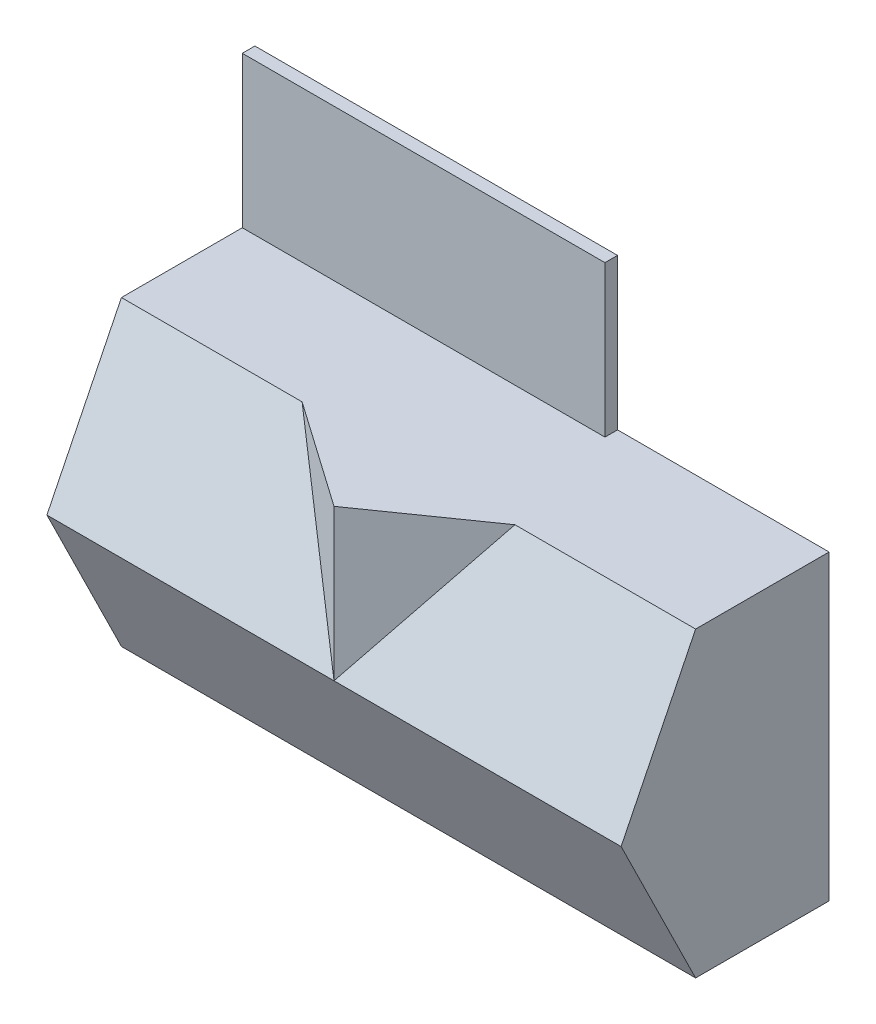
from build123d import *

# Parameters (mm, degrees)
SKETCH3_W           = 11582.4
SKETCH3_H           = 6096
SKETCH3_W_2         = 4341.154286856
SKETCH3_H_2         = 914.4
SKETCH3_W_3         = 1676.4
SKETCH3_H_3         = 2330.801356814
SKETCH3_W_4         = 2663.595025017
SKETCH3_H_4         = 2342.798643186
SKETCH3_W_5         = 1043.645713144
SKETCH3_W_6         = 4013.2
SKETCH3_W_7         = 3708.4
BOSS_EXTRUDE1_DEPTH = 2438.4
SKETCH4_W           = 11582.4
SKETCH4_H           = 6096
BOSS_EXTRUDE2_DEPTH = 254
SKETCH5_W           = 3178.404974983
SKETCH5_H           = 101.6
BOSS_EXTRUDE3_DEPTH = 1016
BOSS_EXTRUDE4_DEPTH = 11582.4
BOSS_EXTRUDE5_REACH = 6098
SKETCH8_W           = 7315.2
SKETCH8_H           = 3048
BOSS_EXTRUDE6_DEPTH = 254


with BuildPart() as part:
    # Sketch3 → Boss-Extrude1 (new body)
    with BuildSketch(Plane.XY):
        with Locations((5791.2, 3048)):
            Rectangle(SKETCH3_W, SKETCH3_H)
        Polygon((152.4, 152.4), (4550.004974983, 152.4), (4550.004974983, 2596.798643186), (5842, 2596.798643186), (5842, 3511.198643186), (5842, 5943.6), (152.4, 5943.6), align=None, mode=Mode.SUBTRACT)
        with Locations((8114.177143428, 3053.998643186)):
            Rectangle(SKETCH3_W_2, SKETCH3_H_2, mode=Mode.SUBTRACT)
        with Locations((6781.8, 4778.199321593)):
            Rectangle(SKETCH3_W_3, SKETCH3_H_3, mode=Mode.SUBTRACT)
        with Locations((5983.402487492, 1323.799321593)):
            Rectangle(SKETCH3_W_4, SKETCH3_H_4, mode=Mode.SUBTRACT)
        with Locations((10908.177143428, 3053.998643186)):
            Rectangle(SKETCH3_W_5, SKETCH3_H_2, mode=Mode.SUBTRACT)
        with Locations((9423.4, 1323.799321593)):
            Rectangle(SKETCH3_W_6, SKETCH3_H_4, mode=Mode.SUBTRACT)
        with Locations((9575.8, 4778.199321593)):
            Rectangle(SKETCH3_W_7, SKETCH3_H_3, mode=Mode.SUBTRACT)
    extrude(amount=BOSS_EXTRUDE1_DEPTH)

    # Sketch4 → Boss-Extrude2 (add)
    with BuildSketch(Plane(origin=(0, 0, 0), x_dir=(-1, 0, 0), z_dir=(0, 0, -1))):
        with Locations((-5791.2, 3048)):
            Rectangle(SKETCH4_W, SKETCH4_H)
    extrude(amount=BOSS_EXTRUDE2_DEPTH)

    # Sketch5 → Boss-Extrude3 (add)
    with BuildSketch(Plane.XY):
        with Locations((1741.602487492, 2545.998643186)):
            Rectangle(SKETCH5_W, SKETCH5_H)
    extrude(amount=BOSS_EXTRUDE3_DEPTH)

    # Sketch6 → Boss-Extrude4 (add)
    with BuildSketch(Plane.ZY):
        Polygon((2438.4, 6096), (2438.4, 0), (3941.507258543, 3048), align=None)
    extrude(amount=-BOSS_EXTRUDE4_DEPTH)

    # Boss-Extrude5: up to this face of the body (flat: up to its plane)
    boss_extrude5_end = Plane(part.part.faces().sort_by_distance((5791.2, 4572, 3189.953629272))[0])
    # Sketch7 → Boss-Extrude5 (add, up to the picked face)
    with BuildSketch(Plane(origin=(0, 6096, 0), x_dir=(1, 0, 0), z_dir=(0, 1, 0)), mode=Mode.PRIVATE) as boss_extrude5_sk1:
        Polygon((7937.859635208, -2438.4), (5791.2, -3941.507258543), (3644.540364792, -2438.4), align=None)
    boss_extrude5_tool1 = split(extrude(boss_extrude5_sk1.sketch, amount=-BOSS_EXTRUDE5_REACH, mode=Mode.PRIVATE), bisect_by=boss_extrude5_end, keep=Keep.BOTH, mode=Mode.PRIVATE)
    add(boss_extrude5_tool1.solids().sort_by_distance((5791.2, 6096, 2939.435753))[0])


with BuildPart() as body_2:
    # Sketch8 → Boss-Extrude6 (new body)
    with BuildSketch(Plane(origin=(0, 0, -254), x_dir=(-1, 0, 0), z_dir=(0, 0, -1))):
        with Locations((-3657.6, 7620)):
            Rectangle(SKETCH8_W, SKETCH8_H)
    extrude(amount=-BOSS_EXTRUDE6_DEPTH)


solid = Compound([part.part, body_2.part])
